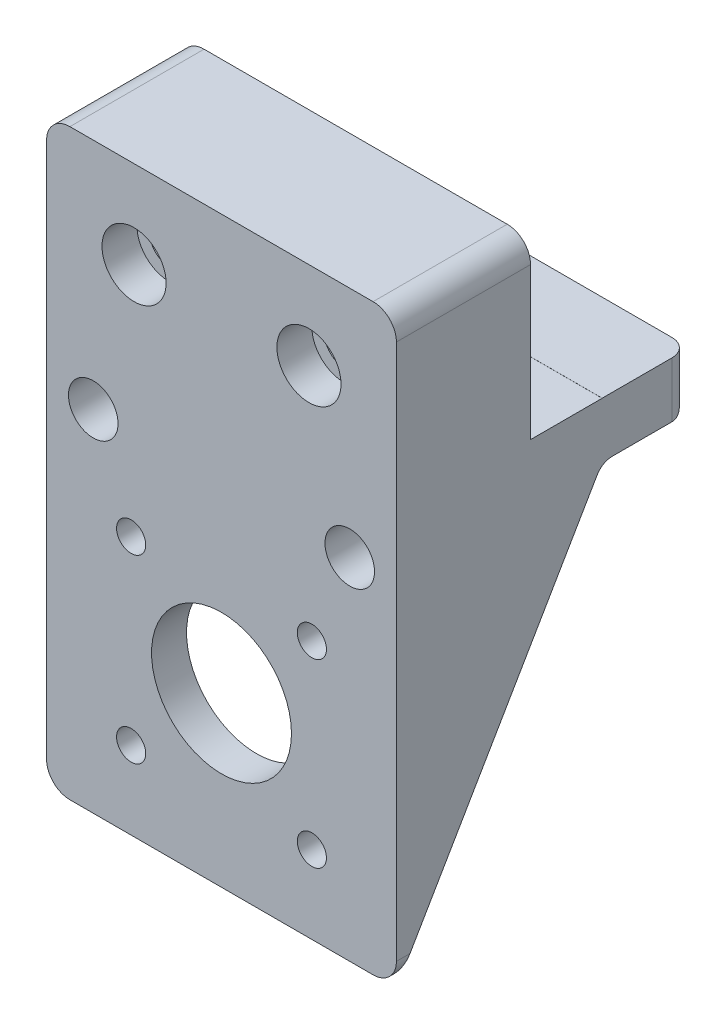
from build123d import *

# Parameters (mm, degrees)
ESBO_O1_R                         = 12
ESBO_O1_R_2                       = 2.5
RESSALTO_EXTRUS_O1_DEPTH          = 6
RESSALTO_EXTRUS_O2_DEPTH          = 50
CORTE_EXTRUS_O1_DEPTH             = 61
ESBO_O5_R                         = 4.25
CORTE_EXTRUS_O2_DEPTH             = 15
REBAIXO_PARA_SHCS_M61_D           = 6.6
REBAIXO_PARA_SHCS_M61_CBORE_D     = 11
REBAIXO_PARA_SHCS_M61_CBORE_DEPTH = 6
CORTE_EXTRUS_O3_DEPTH             = 61
ESBO_O4_W                         = 60
ESBO_O4_H                         = 9.5
RESSALTO_EXTRUS_O3_DEPTH          = 15
FILETE1_R                         = 3


with BuildPart() as part:
    # Esboço1 → Ressalto-extrusão1 (new body)
    with BuildSketch(Plane.XY.offset(29.3)):
        with BuildLine():
            Line((-245.980789633, -100), (-193.980789633, -100))
            ThreePointArc((-193.980789633, -100), (-191.152362508, -98.828427125), (-189.980789633, -96))
            Line((-189.980789633, -96), (-189.980789633, -4))
            ThreePointArc((-189.980789633, -4), (-191.152362508, -1.171572875), (-193.980789633, 0))
            Line((-193.980789633, 0), (-245.980789633, 0))
            ThreePointArc((-245.980789633, 0), (-248.809216758, -1.171572875), (-249.980789633, -4))
            Line((-249.980789633, -4), (-249.980789633, -96))
            ThreePointArc((-249.980789633, -96), (-248.809216758, -98.828427125), (-245.980789633, -100))
        make_face()
        with Locations((-219.980789633, -71.15)):
            Circle(ESBO_O1_R, mode=Mode.SUBTRACT)
        with Locations((-235.480789633, -86.65)):
            Circle(ESBO_O1_R_2, mode=Mode.SUBTRACT)
        with Locations((-235.480789633, -55.65)):
            Circle(ESBO_O1_R_2, mode=Mode.SUBTRACT)
        with Locations((-204.480789633, -86.65)):
            Circle(ESBO_O1_R_2, mode=Mode.SUBTRACT)
        with Locations((-204.480789633, -55.65)):
            Circle(ESBO_O1_R_2, mode=Mode.SUBTRACT)
    extrude(amount=RESSALTO_EXTRUS_O1_DEPTH)

    # Esboço2 → Ressalto-extrusão2 (add)
    with BuildSketch(Plane(origin=(0, 0, 29.3), x_dir=(-1, 0, 0), z_dir=(0, 0, -1))):
        with BuildLine():
            Line((189.980789633, -4), (189.980789633, -96))
            ThreePointArc((189.980789633, -96), (191.152362508, -98.828427125), (193.980789633, -100))
            Line((193.980789633, -100), (245.980789633, -100))
            ThreePointArc((245.980789633, -100), (248.809216758, -98.828427125), (249.980789633, -96))
            Line((249.980789633, -96), (249.980789633, -4))
            ThreePointArc((249.980789633, -4), (248.809216758, -1.171572875), (245.980789633, 0))
            Line((245.980789633, 0), (193.980789633, 0))
            ThreePointArc((193.980789633, 0), (191.152362508, -1.171572875), (189.980789633, -4))
        make_face()
        Polygon((237.959216758, -48), (202.002362508, -48), (196.830789633, -53.171572875), (196.830789633, -89.128427125), (202.002362508, -94.3), (237.959216758, -94.3), (243.130789633, -89.128427125), (243.130789633, -53.171572875), align=None, mode=Mode.SUBTRACT)
    extrude(amount=RESSALTO_EXTRUS_O2_DEPTH)

    # Esboço3 → Corte-extrusão1 (cut, through all)
    with BuildSketch(Plane.ZY.offset(249.980789633)):
        Polygon((35.3, -100), (-20.7, -100), (-20.7, -31.056412858), (0, -31.056412858), (0, -39.485714286), align=None)
    extrude(amount=-CORTE_EXTRUS_O1_DEPTH, mode=Mode.SUBTRACT)

    # Esboço5 → Corte-extrusão2 (cut)
    with BuildSketch(Plane.XY.offset(35.3)):
        with Locations((-241.980789633, -40)):
            Circle(ESBO_O5_R)
        with Locations((-197.980789633, -40)):
            Circle(ESBO_O5_R)
    extrude(amount=-CORTE_EXTRUS_O2_DEPTH, mode=Mode.SUBTRACT)

    # Rebaixo para SHCS M61 (through all)
    with Locations(Plane.XY.offset(35.3)):
        with Locations((-234.980789633, -15), (-204.980789633, -15)):
            CounterBoreHole(REBAIXO_PARA_SHCS_M61_D / 2, REBAIXO_PARA_SHCS_M61_CBORE_D / 2, REBAIXO_PARA_SHCS_M61_CBORE_DEPTH)

    # Esboço10 → Corte-extrusão3 (cut, through all)
    with BuildSketch(Plane.ZY.offset(249.980789633)):
        Polygon((12.291276716, 1.7848e-05), (-27.708723284, 1.7848e-05), (-27.708723284, -29.999982152), (-21.235336221, -29.999982152), (-21.235336221, -31.532793492), (0, -31.532793492), (0, -29.999982152), (12.291276716, -29.999982152), align=None)
    extrude(amount=-CORTE_EXTRUS_O3_DEPTH, mode=Mode.SUBTRACT)

    # Esboço4 → Ressalto-extrusão3 (add)
    with BuildSketch(Plane(origin=(0, 0, 0), x_dir=(-1, 0, 0), z_dir=(0, 0, -1))):
        with Locations((219.980789633, -34.735714286)):
            Rectangle(ESBO_O4_W, ESBO_O4_H)
    extrude(amount=RESSALTO_EXTRUS_O3_DEPTH)

    # Filete1
    filete1_edges = [part.edges().sort_by_distance(p)[0] for p in [
        (-219.980789633, -39.485714286, 0),
        (-189.980789633, -34.735714286, -15),
        (-219.980789633, -39.485714286, -15),
        (-249.980789633, -34.735714286, -15),
    ]]
    fillet(filete1_edges, radius=FILETE1_R)


solid = part.part
